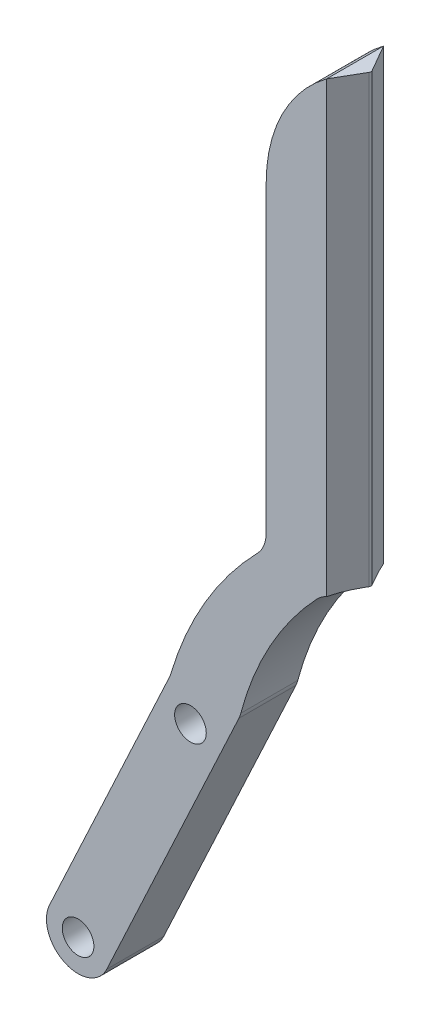
from build123d import *

# Parameters (mm, degrees)
SKETCH1_R           = 2.5
BOSS_EXTRUDE1_DEPTH = 9
SKETCH2_W           = 1.5
SKETCH2_H           = 71.396737885
CUT_EXTRUDE1_DEPTH  = 10
BOSS_EXTRUDE2_DEPTH = 70.368354
FILLET1_R           = 0.5
FILLET2_R           = 5


with BuildPart() as part:
    # Sketch1 → Boss-Extrude1 (new body)
    with BuildSketch(Plane.XY):
        with BuildLine():
            Line((-11.03377919, 0), (-30.129933814, -40.951835747))
            ThreePointArc((-30.129933814, -40.951835747), (-27.711486187, -47.596465991), (-21.066855944, -45.178018364))
            Line((-21.066855944, -45.178018364), (0, 0))
            ThreePointArc((0, 0), (5.707925077, 13.632041213), (15.151572114, 25))
            Line((15.151572114, 25), (15.151572114, 95))
            ThreePointArc((15.151572114, 95), (7.05920736, 86.420861211), (4.117792925, 75))
            Line((4.117792925, 75), (4.117792925, 25))
            ThreePointArc((4.117792925, 25), (-5.106750503, 13.499250648), (-11.03377919, 0))
        make_face()
        with Locations((-25.598394879, -43.064927056)):
            Circle(SKETCH1_R, mode=Mode.SUBTRACT)
        with Locations((-7.848427886, -5)):
            Circle(SKETCH1_R, mode=Mode.SUBTRACT)
    extrude(amount=BOSS_EXTRUDE1_DEPTH)

    # Sketch2 → Cut-Extrude1 (cut, through all)
    with BuildSketch(Plane.XY.offset(9)):
        with Locations((14.401572114, 59.301631058)):
            Rectangle(SKETCH2_W, SKETCH2_H)
    extrude(amount=-CUT_EXTRUDE1_DEPTH, mode=Mode.SUBTRACT)

    # Sketch4 → Boss-Extrude2 (add)
    with BuildSketch(Plane(origin=(0, 93.971615681, 0), x_dir=(0, 0, -1), z_dir=(0, -1, 0))):
        Polygon((0, 13.651572114), (-4.5, 16.249648326), (-9, 13.651572114), align=None)
    extrude(amount=BOSS_EXTRUDE2_DEPTH)

    # Fillet1
    fillet1_edges = [part.edges().sort_by_distance(p)[0] for p in [
        (16.249648326, 58.787438681, 4.5),
    ]]
    fillet(fillet1_edges, radius=FILLET1_R)

    # Fillet2
    fillet2_edges = [part.edges().sort_by_distance(p)[0] for p in [
        (0, 0, 4.5),
        (-11.03377919, 0, 4.5),
        (4.117792925, 25, 4.5),
        (13.651572114, 23.603262115, 4.5),
    ]]
    fillet(fillet2_edges, radius=FILLET2_R)


solid = part.part
